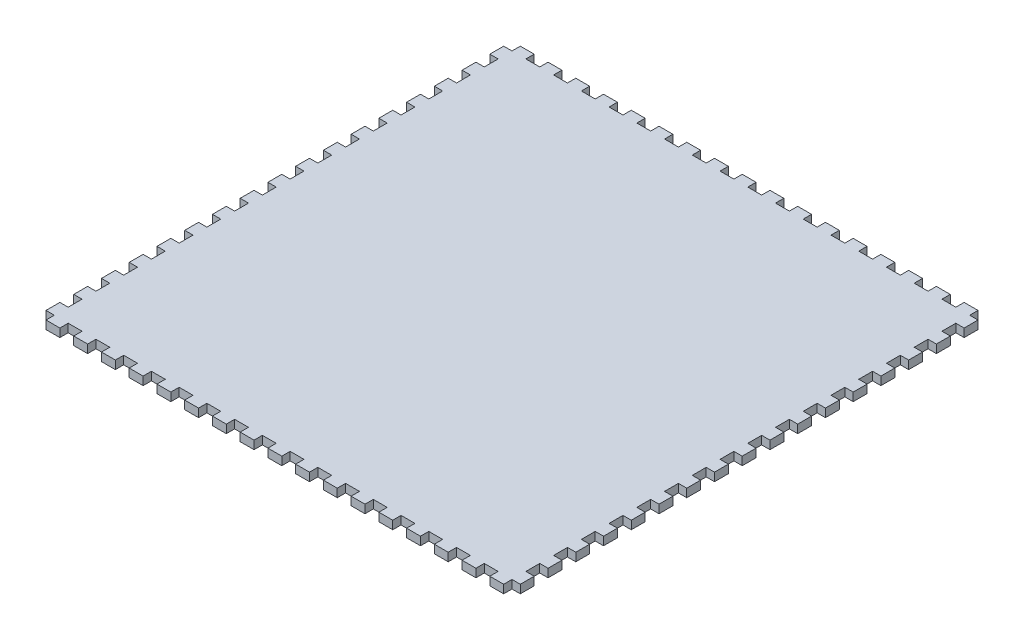
from build123d import *

# Parameters (mm, degrees)
EXTRUDE_2_DEPTH = 3


with BuildPart() as part:
    # Эскиз1 → Бобышка-Вытянуть2 (new body)
    with BuildSketch(Plane(origin=(0, 0, 0), x_dir=(1, 0, 0), z_dir=(0, 1, 0))):
        Polygon((0, 165), (0, 168), (5, 168), (5, 165), (10, 165), (10, 168), (15, 168), (15, 165), (20, 165), (20, 168), (25, 168), (25, 165), (30, 165), (30, 168), (35, 168), (35, 165), (40, 165), (40, 168), (45, 168), (45, 165), (50, 165), (50, 168), (55, 168), (55, 165), (60, 165), (60, 168), (65, 168), (65, 165), (70, 165), (70, 168), (75, 168), (75, 165), (80, 165), (80, 168), (85, 168), (85, 165), (90, 165), (90, 168), (95, 168), (95, 165), (100, 165), (100, 168), (105, 168), (105, 165), (110, 165), (110, 168), (115, 168), (115, 165), (120, 165), (120, 168), (125, 168), (125, 165), (130, 165), (130, 168), (135, 168), (135, 165), (140, 165), (140, 168), (145, 168), (145, 165), (150, 165), (150, 168), (155, 168), (155, 165), (160, 165), (160, 168), (165, 168), (165, 165), (168, 165), (168, 160), (165, 160), (165, 155), (168, 155), (168, 150), (165, 150), (165, 145), (168, 145), (168, 140), (165, 140), (165, 135), (168, 135), (168, 130), (165, 130), (165, 125), (168, 125), (168, 120), (165, 120), (165, 115), (168, 115), (168, 110), (165, 110), (165, 105), (168, 105), (168, 100), (165, 100), (165, 95), (168, 95), (168, 90), (165, 90), (165, 85), (168, 85), (168, 80), (165, 80), (165, 75), (168, 75), (168, 70), (165, 70), (165, 65), (168, 65), (168, 60), (165, 60), (165, 55), (168, 55), (168, 50), (165, 50), (165, 45), (168, 45), (168, 40), (165, 40), (165, 35), (168, 35), (168, 30), (165, 30), (165, 25), (168, 25), (168, 20), (165, 20), (165, 15), (168, 15), (168, 10), (165, 10), (165, 5), (168, 5), (168, 0), (165, 0), (165, -3), (160, -3), (160, 0), (155, 0), (155, -3), (150, -3), (150, 0), (145, 0), (145, -3), (140, -3), (140, 0), (135, 0), (135, -3), (130, -3), (130, 0), (125, 0), (125, -3), (120, -3), (120, 0), (115, 0), (115, -3), (110, -3), (110, 0), (105, 0), (105, -3), (100, -3), (100, 0), (95, 0), (95, -3), (90, -3), (90, 0), (85, 0), (85, -3), (80, -3), (80, 0), (75, 0), (75, -3), (70, -3), (70, 0), (65, 0), (65, -3), (60, -3), (60, 0), (55, 0), (55, -3), (50, -3), (50, 0), (45, 0), (45, -3), (40, -3), (40, 0), (35, 0), (35, -3), (30, -3), (30, 0), (25, 0), (25, -3), (20, -3), (20, 0), (15, 0), (15, -3), (10, -3), (10, 0), (5, 0), (5, -3), (0, -3), (0, 0), (-3, 0), (-3, 5), (0, 5), (0, 10), (-3, 10), (-3, 15), (0, 15), (0, 20), (-3, 20), (-3, 25), (0, 25), (0, 30), (-3, 30), (-3, 35), (0, 35), (0, 40), (-3, 40), (-3, 45), (0, 45), (0, 50), (-3, 50), (-3, 55), (0, 55), (0, 60), (-3, 60), (-3, 65), (0, 65), (0, 70), (-3, 70), (-3, 75), (0, 75), (0, 80), (-3, 80), (-3, 85), (0, 85), (0, 90), (-3, 90), (-3, 95), (0, 95), (0, 100), (-3, 100), (-3, 105), (0, 105), (0, 110), (-3, 110), (-3, 115), (0, 115), (0, 120), (-3, 120), (-3, 125), (0, 125), (0, 130), (-3, 130), (-3, 135), (0, 135), (0, 140), (-3, 140), (-3, 145), (0, 145), (0, 150), (-3, 150), (-3, 155), (0, 155), (0, 160), (-3, 160), (-3, 165), align=None)
    extrude(amount=EXTRUDE_2_DEPTH)


solid = part.part
